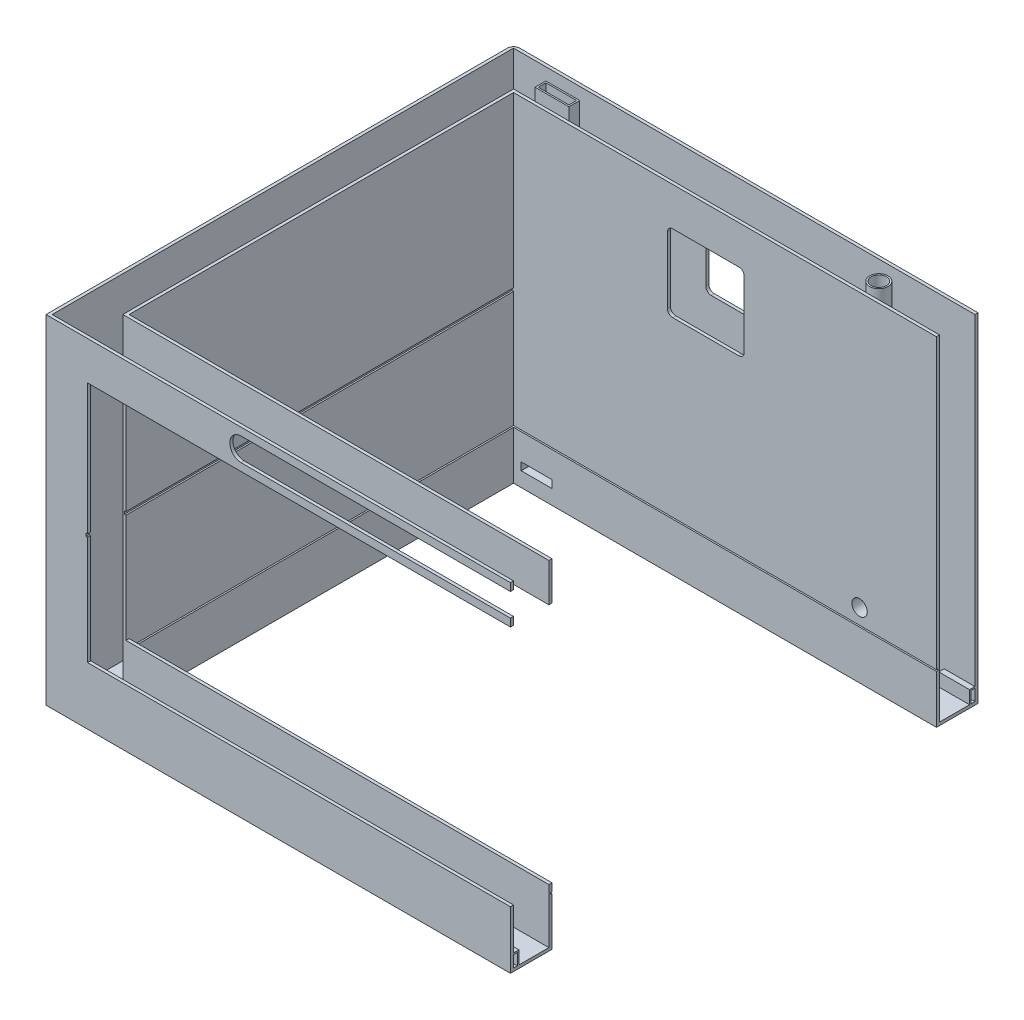
from build123d import *

# Parameters (mm, degrees)
BOSS_EXTRUDE1_DEPTH             = 440
BOSS_EXTRUDE2_DEPTH             = 440
BOSS_EXTRUDE3_DEPTH             = 4
SKETCH4_W                       = 500
SKETCH4_H                       = 4
CUT_EXTRUDE1_DEPTH              = 2
CUT_EXTRUDE3_DEPTH              = 1
CUT_EXTRUDE3_DEPTH_BACK         = 1
CUT_EXTRUDE6_DEPTH              = 54
BOSS_EXTRUDE6_DEPTH             = 40
BOSS_EXTRUDE5_DEPTH             = 40
CUT_EXTRUDE9_DEPTH              = 4
SKETCH14_W                      = 100
SKETCH14_H                      = 100
CUT_EXTRUDE10_DEPTH             = 931.23222907
FILLET1_R                       = 7
FILLET2_R                       = 8
CUT_EXTRUDE11_DEPTH             = 2
SKETCH17_W                      = 40
SKETCH17_H                      = 10
CUT_EXTRUDE12_DEPTH             = 10
SKETCH18_W                      = 44
SKETCH18_H                      = 14
SKETCH18_W_2                    = 40
SKETCH18_H_2                    = 10
BOSS_EXTRUDE7_DEPTH             = 436
CUT_EXTRUDE13_REACH             = 944.28
SKETCH19_W                      = 40
SKETCH19_H                      = 10
CUT_EXTRUDE13_DIRECTION_2_DEPTH = 2
SKETCH20_W                      = 44
SKETCH20_H                      = 14
SKETCH20_W_2                    = 40
SKETCH20_H_2                    = 10
BOSS_EXTRUDE8_DEPTH             = 16
SKETCH21_R                      = 10
CUT_EXTRUDE14_DEPTH             = 25
SKETCH25_R                      = 12
SKETCH25_R_2                    = 10
BOSS_EXTRUDE10_DEPTH            = 17
SKETCH22_R                      = 10
CUT_EXTRUDE15_DEPTH             = 4
SKETCH23_R                      = 12
SKETCH23_R_2                    = 10
BOSS_EXTRUDE9_DEPTH             = 436


with BuildPart() as part:
    # Sketch1 → Boss-Extrude1 (new body)
    with BuildSketch(Plane(origin=(0, 0, 0), x_dir=(1, 0, 0), z_dir=(0, 1, 0))):
        Polygon((0, 300), (-600, 300), (-600, -300), (0, -300), (0, -304), (-604, -304), (-604, 304), (0, 304), align=None)
    extrude(amount=BOSS_EXTRUDE1_DEPTH)



with BuildPart() as body_2:
    # Sketch2 → Boss-Extrude2 (new body)
    with BuildSketch(Plane(origin=(0, 0, 0), x_dir=(1, 0, 0), z_dir=(0, 1, 0))):
        Polygon((0, 250), (-550, 250), (-550, -250), (0, -250), (0, -254), (-554, -254), (-554, 254), (0, 254), align=None)
    extrude(amount=BOSS_EXTRUDE2_DEPTH)


with BuildPart() as part_1:
    add(part.part)

    add(body_2.part)  # Boss-Extrude3 merges body 2
    # Sketch3 → Boss-Extrude3 (add)
    with BuildSketch(Plane(origin=(0, 0, 0), x_dir=(1, 0, 0), z_dir=(0, 1, 0))):
        Polygon((0, -254), (0, -300), (-600, -300), (-600, 300), (0, 300), (0, 254), (-554, 254), (-554, -254), align=None)
    extrude(amount=BOSS_EXTRUDE3_DEPTH)

    # Sketch4 → Cut-Extrude1 (cut)
    with BuildSketch(Plane(origin=(-550, 0, 0), x_dir=(0, 0, -1), z_dir=(1, 0, 0))):
        with Locations((0, 218)):
            Rectangle(SKETCH4_W, SKETCH4_H)
    extrude(amount=-CUT_EXTRUDE1_DEPTH, mode=Mode.SUBTRACT)

    # Sketch7 → Cut-Extrude3 (cut, two sides)
    with BuildSketch(Plane(origin=(0, 64, 0), x_dir=(1, 0, 0), z_dir=(0, 1, 0))) as cut_extrude3_sk:
        Polygon((-550, 250), (0, 250), (0, 252), (-552, 252), (-552, -252), (0, -252), (0, -250), (-550, -250), align=None)
    extrude(amount=CUT_EXTRUDE3_DEPTH, mode=Mode.SUBTRACT)
    extrude(cut_extrude3_sk.sketch, amount=-CUT_EXTRUDE3_DEPTH_BACK, mode=Mode.SUBTRACT)

    # Sketch10 → Cut-Extrude6 (cut)
    with BuildSketch(Plane.XY.offset(304)):
        Polygon((0, 390), (-550, 390), (-550, 220), (-552, 220), (-552, 216), (-550, 216), (-550, 75), (0, 75), align=None)
    extrude(amount=-CUT_EXTRUDE6_DEPTH, mode=Mode.SUBTRACT)

    # Sketch11 → Boss-Extrude6 (add)
    with BuildSketch(Plane(origin=(0, 0, 0), x_dir=(0, 0, -1), z_dir=(1, 0, 0))):
        Polygon((-295, 4), (-295, 19), (-300, 19), (-300, 21), (-293, 21), (-293, 4), align=None)
    extrude(amount=-BOSS_EXTRUDE6_DEPTH)

    # Sketch12 → Boss-Extrude5 (add)
    with BuildSketch(Plane(origin=(0, 0, 0), x_dir=(0, 0, -1), z_dir=(1, 0, 0))):
        Polygon((295, 4), (293, 4), (293, 21), (300, 21), (300, 19), (295, 19), align=None)
    extrude(amount=-BOSS_EXTRUDE5_DEPTH)

    # Sketch13 → Cut-Extrude9 (cut)
    with BuildSketch(Plane.XY.offset(304)):
        with BuildLine():
            Line((0, 400), (0, 430))
            Line((0, 430), (-350, 430))
            ThreePointArc((-350, 430), (-365, 415), (-350, 400))
            Line((-350, 400), (0, 400))
        make_face()
    extrude(amount=-CUT_EXTRUDE9_DEPTH, mode=Mode.SUBTRACT)

    # Sketch14 → Cut-Extrude10 (cut, through all)
    with BuildSketch(Plane.XY.offset(-250)):
        with Locations((-300, 340)):
            Rectangle(SKETCH14_W, SKETCH14_H)
    extrude(amount=-CUT_EXTRUDE10_DEPTH, mode=Mode.SUBTRACT)

    # Fillet1
    fillet1_edges = [part_1.edges().sort_by_distance(p)[0] for p in [
        (-350, 290, -302),
        (-350, 290, -252),
        (-350, 390, -302),
        (-350, 390, -252),
        (-250, 390, -302),
        (-250, 390, -252),
        (-250, 290, -302),
        (-250, 290, -252),
    ]]
    fillet(fillet1_edges, radius=FILLET1_R)

    # Fillet2
    fillet2_edges = [part_1.edges().sort_by_distance(p)[0] for p in [
        (-604, 220, -304),
    ]]
    fillet(fillet2_edges, radius=FILLET2_R)

    # Sketch15 → Cut-Extrude11 (cut)
    with BuildSketch(Plane.XZ):
        Polygon((-600, 300), (-600, 288), (-598, 288), (-598, 298), (-588, 298), (-588, 300), align=None)
    cut_extrude11 = extrude(amount=-CUT_EXTRUDE11_DEPTH, mode=Mode.SUBTRACT)

    # Mirror1: Cut-Extrude11 across plane
    add(cut_extrude11.mirror(Plane.XY), mode=Mode.SUBTRACT)

    # Sketch17 → Cut-Extrude12 (cut)
    with BuildSketch(Plane(origin=(0, 4, 0), x_dir=(1, 0, 0), z_dir=(0, 1, 0))):
        with Locations((-520, 277)):
            Rectangle(SKETCH17_W, SKETCH17_H)
    extrude(amount=-CUT_EXTRUDE12_DEPTH, mode=Mode.SUBTRACT)

    # Sketch18 → Boss-Extrude7 (add)
    with BuildSketch(Plane(origin=(0, 4, 0), x_dir=(1, 0, 0), z_dir=(0, 1, 0))):
        with Locations((-520, 277)):
            Rectangle(SKETCH18_W, SKETCH18_H)
        with Locations((-520, 277)):
            Rectangle(SKETCH18_W_2, SKETCH18_H_2, mode=Mode.SUBTRACT)
    extrude(amount=BOSS_EXTRUDE7_DEPTH)

    # Cut-Extrude13: up to this face of the body (flat: up to its plane)
    cut_extrude13_end = Plane(part_1.part.faces().sort_by_distance((-273.743044457, 248.059881287, -250))[0])
    # Sketch19 → Cut-Extrude13 (cut, up to the picked face)
    with BuildSketch(Plane.XY.offset(-270), mode=Mode.PRIVATE) as cut_extrude13_sk1:
        with Locations((-520, 24)):
            Rectangle(SKETCH19_W, SKETCH19_H)
    cut_extrude13_tool1 = split(extrude(cut_extrude13_sk1.sketch, amount=CUT_EXTRUDE13_REACH, mode=Mode.PRIVATE), bisect_by=cut_extrude13_end, keep=Keep.BOTH, mode=Mode.PRIVATE)
    add(cut_extrude13_tool1.solids().sort_by(Axis((-520, 24, -270), (0, 0, 1)))[0], mode=Mode.SUBTRACT)

    # Sketch19 → Cut-Extrude13 direction 2 (cut)
    with BuildSketch(Plane.XY.offset(-270)):
        with Locations((-520, 24)):
            Rectangle(SKETCH19_W, SKETCH19_H)
    extrude(amount=-CUT_EXTRUDE13_DIRECTION_2_DEPTH, mode=Mode.SUBTRACT)

    # Sketch20 → Boss-Extrude8 (add)
    with BuildSketch(Plane.XY.offset(-270)):
        with Locations((-520, 24)):
            Rectangle(SKETCH20_W, SKETCH20_H)
        with Locations((-520, 24)):
            Rectangle(SKETCH20_W_2, SKETCH20_H_2, mode=Mode.SUBTRACT)
    extrude(amount=BOSS_EXTRUDE8_DEPTH)

    # Sketch21 → Cut-Extrude14 (cut)
    with BuildSketch(Plane.XY.offset(-250)):
        with Locations((-100, 85)):
            Circle(SKETCH21_R)
    extrude(amount=-CUT_EXTRUDE14_DEPTH, mode=Mode.SUBTRACT)

    # Sketch25 → Boss-Extrude10 (add)
    with BuildSketch(Plane(origin=(0, 0, -254), x_dir=(-1, 0, 0), z_dir=(0, 0, -1))):
        with Locations(Location((100, 85, 0), (0, 0, 180))):
            Circle(SKETCH25_R)
        with Locations(Location((100, 85, 0), (0, 0, 180))):
            Circle(SKETCH25_R_2, mode=Mode.SUBTRACT)
    extrude(amount=BOSS_EXTRUDE10_DEPTH)

    # Sketch22 → Cut-Extrude15 (cut)
    with BuildSketch(Plane(origin=(0, 4, 0), x_dir=(1, 0, 0), z_dir=(0, 1, 0))):
        with Locations(Location((-100, 275, 0), (0, 0, 270))):
            Circle(SKETCH22_R)
    extrude(amount=-CUT_EXTRUDE15_DEPTH, mode=Mode.SUBTRACT)

    # Sketch23 → Boss-Extrude9 (add)
    with BuildSketch(Plane(origin=(0, 4, 0), x_dir=(1, 0, 0), z_dir=(0, 1, 0))):
        with Locations(Location((-100, 275, 0), (0, 0, 90))):
            Circle(SKETCH23_R)
        with Locations(Location((-100, 275, 0), (0, 0, 270))):
            Circle(SKETCH23_R_2, mode=Mode.SUBTRACT)
    extrude(amount=BOSS_EXTRUDE9_DEPTH)


solid = part_1.part
